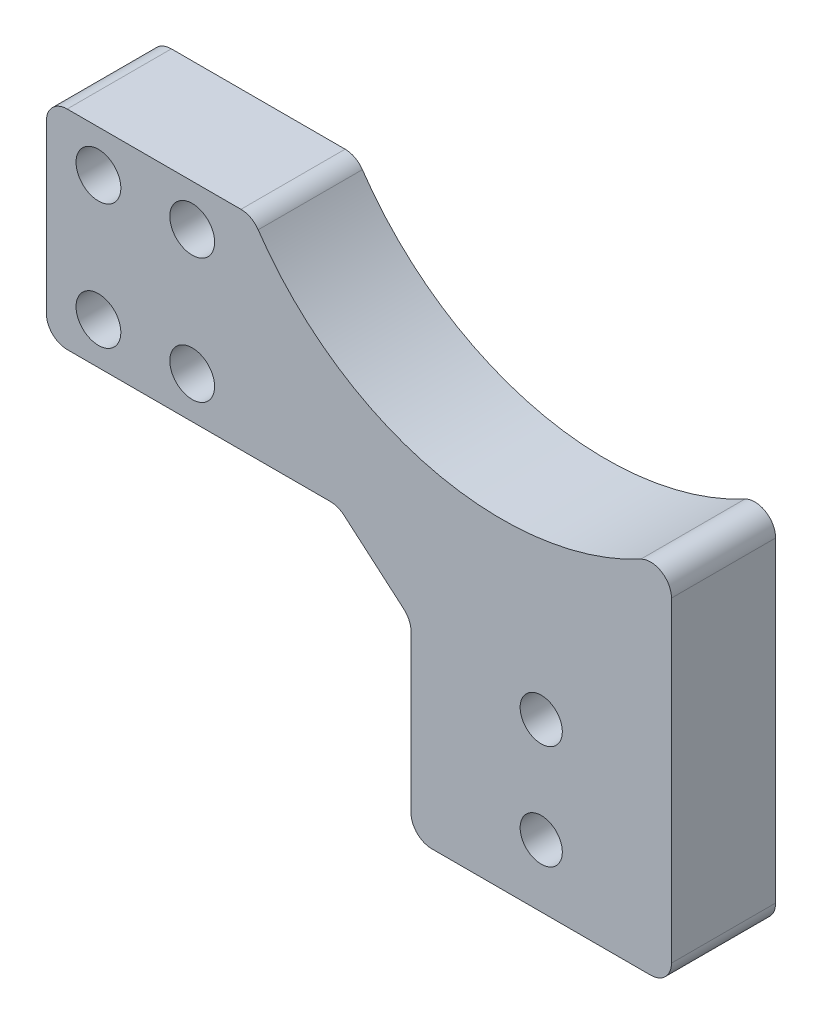
from build123d import *

# Parameters (mm, degrees)
EXTRUDE_1_DEPTH          = 5
FILLET_1_R               = 2
FILLET_2_R               = 2
SKETCH_2_R               = 2.025
CUT_EXTRUDE_1_DEPTH      = 11
SKETCH_3_W               = 25
SKETCH_3_H               = 6
CUT_EXTRUDE_2_DEPTH      = 11
FILLET_3_R               = 2
SKETCH_4_R               = 2.15
CUT_EXTRUDE_3_DEPTH      = 1
CUT_EXTRUDE_3_DEPTH_BACK = 11
SKETCH_5_R               = 2.15
CUT_EXTRUDE_4_DEPTH      = 1
CUT_EXTRUDE_4_DEPTH_BACK = 11


with BuildPart() as part:
    # 草图1 → 凸台-拉伸1 (new body, symmetric)
    with BuildSketch(Plane.XY):
        with BuildLine():
            Line((0, 0), (0, -24))
            Line((0, -24), (25, -24))
            Line((25, -24), (25, 17.926801262))
            ThreePointArc((25, 17.926801262), (3.142873043, 13.301970467), (-15.238723859, 26))
            Line((-15.238723859, 26), (-35, 26))
            Line((-35, 26), (-35, 6))
            Line((-35, 6), (-7, 6))
            Line((-7, 6), (0, 0))
        make_face()
    extrude(amount=EXTRUDE_1_DEPTH, both=True)

    # 圆角1
    fillet_1_edges = [part.edges().sort_by_distance(p)[0] for p in [
        (-7, 6, 0),
        (-35, 6, 0),
        (-35, 26, 0),
        (25, -24, 0),
        (0, -24, 0),
        (0, 0, 0),
    ]]
    fillet(fillet_1_edges, radius=FILLET_1_R)

    # 圆角2
    fillet_2_edges = [part.edges().sort_by_distance(p)[0] for p in [
        (-15.238723859, 26, 0),
        (25, 17.926801262, 0),
    ]]
    fillet(fillet_2_edges, radius=FILLET_2_R)

    # 草图2 → 切除-拉伸1 (cut, through all)
    with BuildSketch(Plane.XY.offset(5)):
        with Locations((12.5, -2)):
            Circle(SKETCH_2_R)
        with Locations((12.5, -12)):
            Circle(SKETCH_2_R)
    extrude(amount=-CUT_EXTRUDE_1_DEPTH, mode=Mode.SUBTRACT)

    # 草图3 → 切除-拉伸2 (cut, through all)
    with BuildSketch(Plane.XY.offset(5)):
        with Locations((12.5, -21)):
            Rectangle(SKETCH_3_W, SKETCH_3_H)
    extrude(amount=-CUT_EXTRUDE_2_DEPTH, mode=Mode.SUBTRACT)

    # 圆角3
    fillet_3_edges = [part.edges().sort_by_distance(p)[0] for p in [
        (0, -18, 0),
        (25, -18, 0),
    ]]
    fillet(fillet_3_edges, radius=FILLET_3_R)

    # 草图4 → 切除-拉伸3 (cut, two sides)
    with BuildSketch(Plane.XY.offset(5)) as cut_extrude_3_sk:
        with Locations((-30, 22)):
            Circle(SKETCH_4_R)
        with Locations((-30, 10)):
            Circle(SKETCH_4_R)
    extrude(amount=CUT_EXTRUDE_3_DEPTH, mode=Mode.SUBTRACT)
    extrude(cut_extrude_3_sk.sketch, amount=-CUT_EXTRUDE_3_DEPTH_BACK, mode=Mode.SUBTRACT)

    # 草图5 → 切除-拉伸4 (cut, two sides)
    with BuildSketch(Plane.XY.offset(5)) as cut_extrude_4_sk:
        with Locations((-21, 10)):
            Circle(SKETCH_5_R)
        with Locations((-21, 22)):
            Circle(SKETCH_5_R)
    extrude(amount=CUT_EXTRUDE_4_DEPTH, mode=Mode.SUBTRACT)
    extrude(cut_extrude_4_sk.sketch, amount=-CUT_EXTRUDE_4_DEPTH_BACK, mode=Mode.SUBTRACT)


solid = part.part
